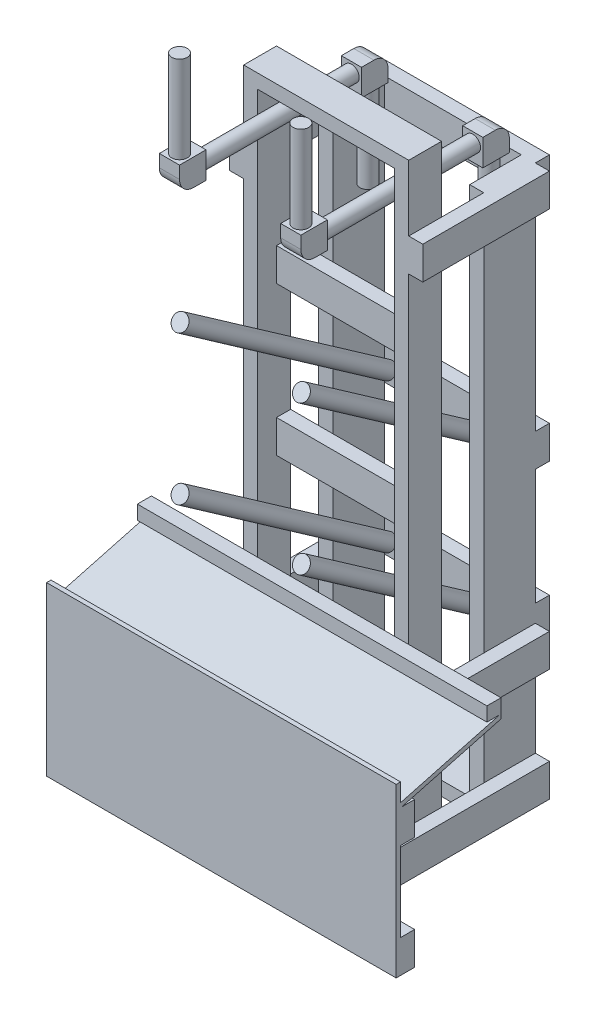
from build123d import *

# Parameters (mm, degrees)
SKETCH1_W            = 946.658829024
SKETCH1_H            = 454.025
BOSS_EXTRUDE3_DEPTH  = 11.90625
SKETCH5_W            = 21.082
SKETCH5_H            = 254
SKETCH6_W            = 457.2
SKETCH6_H            = 21.082
SKETCH7_W            = 21.082
SKETCH7_H            = 254
SKETCH8_W            = 71.755
SKETCH8_H            = 71.755
BOSS_EXTRUDE2_DEPTH  = 27.305
FILLET1_R            = 38.1
SKETCH10_W           = 446.9765
SKETCH10_H           = 1651
SKETCH10_W_2         = 370.7765
SKETCH10_H_2         = 1574.8
BOSS_EXTRUDE4_DEPTH  = 88.9
BOSS_EXTRUDE5_DEPTH  = 139.7
BOSS_EXTRUDE6_DEPTH  = 946.658829
SKETCH13_W           = 38.1
SKETCH13_H           = 88.9
BOSS_EXTRUDE7_DEPTH  = 223.48825
BOSS_EXTRUDE8_DEPTH  = 88.9
SKETCH16_W           = 38.1
SKETCH16_H           = 88.9
BOSS_EXTRUDE9_DEPTH  = 576.798407
SKETCH17_W           = 38.1
SKETCH17_H           = 88.9
BOSS_EXTRUDE10_DEPTH = 342.9
SKETCH19_W           = 38.1
SKETCH19_H           = 88.9
BOSS_EXTRUDE11_DEPTH = 370.7765


with BuildPart() as part:
    # Sketch1 → Boss-Extrude3 (new body)
    with BuildSketch(Plane.XY.offset(831.736844651)):
        with Locations((0, 227.0125)):
            Rectangle(SKETCH1_W, SKETCH1_H)
    extrude(amount=-BOSS_EXTRUDE3_DEPTH)



with BuildPart() as body_2:
    # Sketch3 → Revolve1 (revolve)
    with BuildSketch(Plane(origin=(164.30625, 0, 0), x_dir=(0, 0, -1), z_dir=(1, 0, 0))):
        Polygon((-779.254107605, 789.777894914), (-217.024326356, 396.100363878), (-204.932187925, 413.369727275), (-767.161969174, 807.047258312), align=None)
    revolve(axis=Axis((164.30625, 789.777894914, 779.254107605), (0, -0.573576436, -0.819152044)))


with BuildPart() as body_3:
    # Sketch4 → Revolve2 (revolve)
    with BuildSketch(Plane(origin=(164.30625, 0, 0), x_dir=(0, 0, -1), z_dir=(1, 0, 0))):
        Polygon((-779.254107605, 1192.877664024), (-217.024326356, 799.200132988), (-204.932187925, 816.469496385), (-767.161969174, 1210.147027422), align=None)
    revolve(axis=Axis((164.30625, 1192.877664024, 779.254107605), (0, -0.573576436, -0.819152044)))


with BuildPart() as body_4:
    # Sketch5 → Revolve3 (revolve)
    with BuildSketch(Plane(origin=(164.30625, 0, 0), x_dir=(0, 0, -1), z_dir=(1, 0, 0))):
        with Locations((-791.291187925, 1698.487839746)):
            Rectangle(SKETCH5_W, SKETCH5_H)
    revolve(axis=Axis((164.30625, 1825.487839746, 780.750187925), (0, -1, 0)))



with BuildPart() as body_5:
    # Sketch6 → Revolve4 (revolve)
    with BuildSketch(Plane(origin=(164.30625, 0, 0), x_dir=(0, 0, -1), z_dir=(1, 0, 0))):
        with Locations((-525.734187925, 1555.612839746)):
            Rectangle(SKETCH6_W, SKETCH6_H)
    revolve(axis=Axis((164.30625, 1545.071839746, 754.334187925), (0, 0, -1)))


with BuildPart() as body_6:
    # Sketch7 → Revolve5 (revolve)
    with BuildSketch(Plane(origin=(164.30625, 0, 0), x_dir=(0, 0, -1), z_dir=(1, 0, 0))):
        with Locations((-260.177187925, 1391.655839746)):
            Rectangle(SKETCH7_W, SKETCH7_H)
    revolve(axis=Axis((164.30625, 1518.655839746, 270.718187925), (0, -1, 0)))


with BuildPart() as body_4_1:
    add(body_4.part)

    add(body_5.part)  # Boss-Extrude2 merges body 5

    add(body_6.part)  # Boss-Extrude2 merges body 6
    # Sketch8 → Boss-Extrude2 (add, symmetric)
    with BuildSketch(Plane(origin=(164.30625, 0, 0), x_dir=(0, 0, -1), z_dir=(1, 0, 0))):
        with Locations((-772.177687925, 1553.644339746)):
            Rectangle(SKETCH8_W, SKETCH8_H)
        with Locations((-279.290687925, 1536.499339746)):
            Rectangle(SKETCH8_W, SKETCH8_H)
    extrude(amount=BOSS_EXTRUDE2_DEPTH, both=True)

    # Fillet1
    fillet1_edges = [body_4_1.edges().sort_by_distance(p)[0] for p in [
        (164.30625, 1517.766839746, 808.055187925),
        (164.30625, 1572.376839746, 243.413187925),
    ]]
    fillet(fillet1_edges, radius=FILLET1_R)


with BuildPart() as body_5_2:
    # Sketch10 → Boss-Extrude4 (new body)
    with BuildSketch(Plane.XY.offset(547.832187925)):
        with Locations((0, 825.5)):
            Rectangle(SKETCH10_W, SKETCH10_H)
        with Locations((0, 825.5)):
            Rectangle(SKETCH10_W_2, SKETCH10_H_2, mode=Mode.SUBTRACT)
    extrude(amount=-BOSS_EXTRUDE4_DEPTH)


with BuildPart() as body_6_2:
    # Sketch11 → Boss-Extrude5 (new body)
    with BuildSketch(Plane.XY.offset(344.632187925)):
        Polygon((223.48825, 1473.2), (185.38825, 1473.2), (185.38825, 38.1), (-185.38825, 38.1), (-185.38825, 1473.2), (-223.48825, 1473.2), (-223.48825, 0), (223.48825, 0), align=None)
    extrude(amount=-BOSS_EXTRUDE5_DEPTH)

    # Sketch13 → Boss-Extrude7 (add, symmetric)
    with BuildSketch(Plane(origin=(0, 0, 0), x_dir=(0, 0, -1), z_dir=(1, 0, 0))):
        with Locations((-185.882187925, 396.100363878)):
            Rectangle(SKETCH13_W, SKETCH13_H)
        with Locations((-185.882187925, 799.200132988)):
            Rectangle(SKETCH13_W, SKETCH13_H)
        with Locations((-185.882187925, 1428.75)):
            Rectangle(SKETCH13_W, SKETCH13_H)
    extrude(amount=BOSS_EXTRUDE7_DEPTH, both=True)


with BuildPart() as part_1:
    add(part.part)

    add(body_5_2.part)  # Boss-Extrude6 merges body 5 2
    # Sketch12 → Boss-Extrude6 (add)
    with BuildSketch(Plane(origin=(473.329414512, 0, 0), x_dir=(0, 0, -1), z_dir=(1, 0, 0))):
        Polygon((-781.730594651, 393.638059511), (-816.749030395, 393.638059511), (-819.830594651, 393.638059511), (-819.830594651, 304.738059511), (-781.730594651, 304.738059511), align=None)
        Polygon((-547.832187925, 465.694110282), (-547.832187925, 477.194664652), (-550.913752181, 477.194664652), (-819.830594651, 405.138613881), (-819.830594651, 393.638059511), (-816.749030395, 393.638059511), align=None)
        Polygon((-547.832187925, 477.194664652), (-547.832187925, 515.294664652), (-585.932187925, 515.294664652), (-585.932187925, 477.194664652), (-550.913752181, 477.194664652), align=None)
    extrude(amount=-BOSS_EXTRUDE6_DEPTH)


    add(body_6_2.part)  # Boss-Extrude8 merges body 6 2
    # Sketch14 → Boss-Extrude8 (add)
    with BuildSketch(Plane.XZ):
        Polygon((473.329414512, 819.830594651), (-473.329414512, 819.830594651), (-473.329414512, 781.730594651), (-261.58825, 781.730594651), (-261.58825, 204.932187925), (-223.48825, 204.932187925), (-223.48825, 781.730594651), (223.48825, 781.730594651), (223.48825, 204.932187925), (261.58825, 204.932187925), (261.58825, 781.730594651), (473.329414512, 781.730594651), align=None)
    extrude(amount=-BOSS_EXTRUDE8_DEPTH)

    # Sketch16 → Boss-Extrude9 (add)
    with BuildSketch(Plane(origin=(0, 0, 781.730594651), x_dir=(-1, 0, 0), z_dir=(0, 0, -1))):
        with Locations((-242.53825, 349.188059511)):
            Rectangle(SKETCH16_W, SKETCH16_H)
        with Locations((242.53825, 349.188059511)):
            Rectangle(SKETCH16_W, SKETCH16_H)
    extrude(amount=BOSS_EXTRUDE9_DEPTH)

    # Sketch17 → Boss-Extrude10 (add)
    with BuildSketch(Plane(origin=(0, 0, 204.932187925), x_dir=(-1, 0, 0), z_dir=(0, 0, -1))):
        with Locations((-242.53825, 1428.75)):
            Rectangle(SKETCH17_W, SKETCH17_H)
        with Locations((242.53825, 1428.75)):
            Rectangle(SKETCH17_W, SKETCH17_H)
    extrude(amount=-BOSS_EXTRUDE10_DEPTH)

    # Sketch19 → Boss-Extrude11 (add)
    with BuildSketch(Plane(origin=(-185.38825, 0, 0), x_dir=(0, 0, -1), z_dir=(1, 0, 0))):
        with Locations((-477.982187925, 1176.575854005)):
            Rectangle(SKETCH19_W, SKETCH19_H)
        with Locations((-477.982187925, 773.476084641)):
            Rectangle(SKETCH19_W, SKETCH19_H)
    extrude(amount=BOSS_EXTRUDE11_DEPTH)


with BuildPart() as body_5_3:
    # Mirror1: mirrored copy
    add(body_2.part.mirror(Plane(origin=(0, 0, 0), x_dir=(0, 0, 1), z_dir=(1, 0, 0))))


with BuildPart() as body_6_3:
    # Mirror1 2: mirrored copy
    add(body_3.part.mirror(Plane(origin=(0, 0, 0), x_dir=(0, 0, 1), z_dir=(1, 0, 0))))


with BuildPart() as body_7:
    # Mirror1 3: mirrored copy
    add(body_4_1.part.mirror(Plane(origin=(0, 0, 0), x_dir=(0, 0, 1), z_dir=(1, 0, 0))))


solid = Compound([body_2.part, body_3.part, body_4_1.part, part_1.part, body_5_3.part, body_6_3.part, body_7.part])
